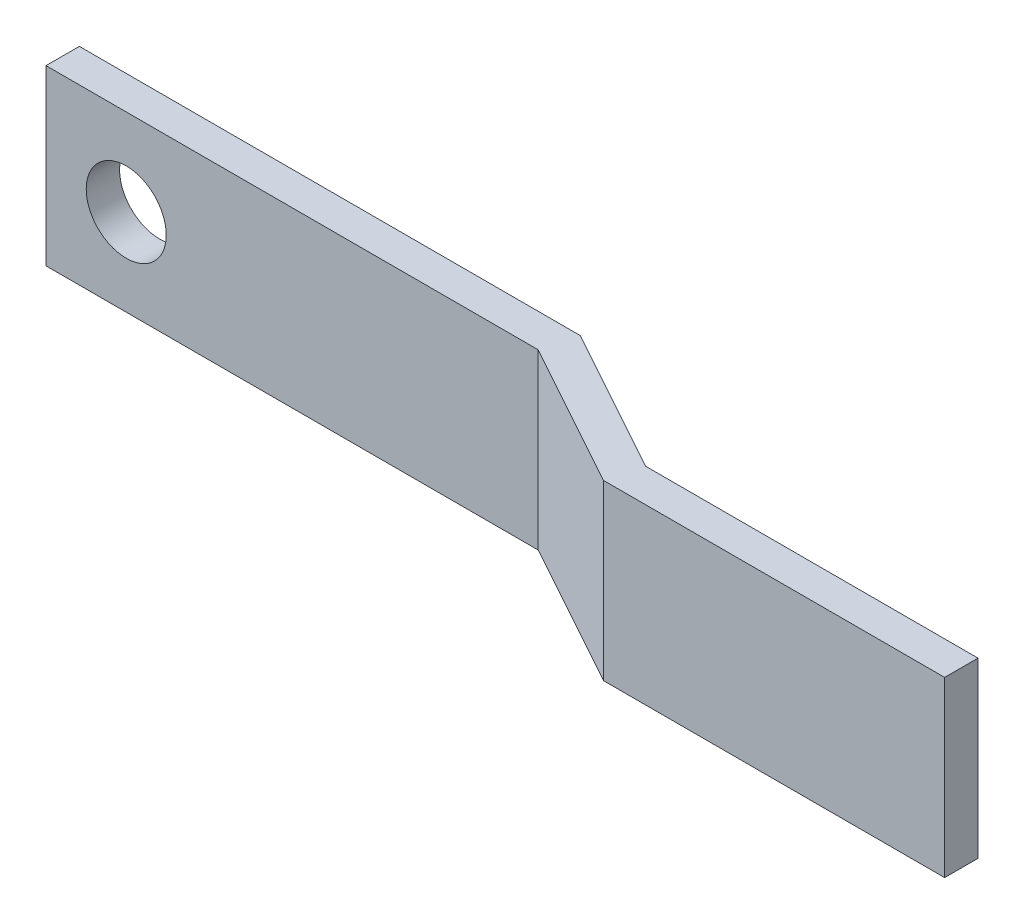
from build123d import *

# Parameters (mm, degrees)
EXTRUDE_THIN1_DEPTH = 13.208
CUT_EXTRUDE1_REACH  = 10.669
SKETCH3_R           = 3.048


with BuildPart() as part:
    # Sketch1 → Extrude-Thin1 (new body)
    with BuildSketch(Plane(origin=(0, 0, 0), x_dir=(1, 0, 0), z_dir=(0, 1, 0))):
        Polygon((0, 0), (38.139058105, 0), (49.245270394, -6.128868698), (74.567434413, -6.128868698), (74.567434413, -8.668868698), (48.590941352, -8.668868698), (37.484729063, -2.54), (0, -2.54), align=None)
    extrude(amount=EXTRUDE_THIN1_DEPTH)

    # Sketch3 → Cut-Extrude1 (cut, up to next)
    with BuildSketch(Plane(origin=(0, 0, 0), x_dir=(-1, 0, 0), z_dir=(0, 0, -1)), mode=Mode.PRIVATE) as cut_extrude1_sk1:
        with Locations((-6.110625798, 6.604)):
            Circle(SKETCH3_R)
    cut_extrude1_tool1 = extrude(cut_extrude1_sk1.sketch, amount=-CUT_EXTRUDE1_REACH, mode=Mode.PRIVATE) & part.part
    add(cut_extrude1_tool1.solids().sort_by_distance((6.110626, 6.604, 0))[0], mode=Mode.SUBTRACT)


solid = part.part
